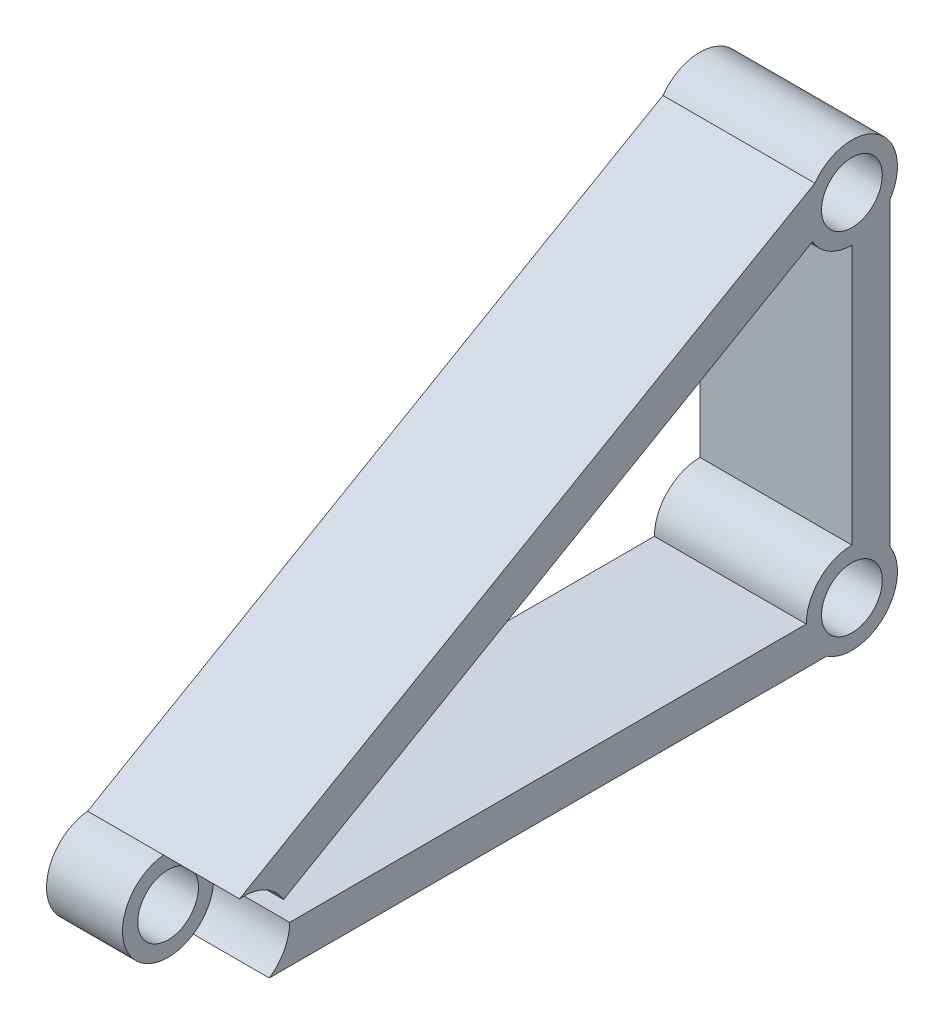
from build123d import *

# Parameters (mm, degrees)
SKETCH2_R           = 40
BOSS_EXTRUDE1_DEPTH = 200
CUT_EXTRUDE1_START  = 200
SKETCH4_R           = 60
CUT_EXTRUDE1_DEPTH  = 100


with BuildPart() as part:
    # Sketch2 → Boss-Extrude1 (new body)
    with BuildSketch(Plane(origin=(0, 0, 0), x_dir=(0, 0, -1), z_dir=(1, 0, 0))):
        with BuildLine():
            ThreePointArc((1495.529247778, 67.272238992), (1475.827854944, 88.899495683), (1468.695495681, 117.272238992))
            Line((1468.695495681, 117.272238992), (788.695495681, 117.272238992))
            ThreePointArc((788.695495681, 117.272238992), (781.563136418, 88.899495683), (761.861743585, 67.272238992))
            Line((761.861743585, 67.272238992), (1495.529247778, 67.272238992))
        make_face()
        with BuildLine():
            Line((780.657019908, 147.272238992), (1476.733971454, 549.152454344))
            ThreePointArc((1476.733971454, 549.152454344), (1468.769326722, 582.128067523), (1479.961523957, 614.152454344))
            Line((1479.961523957, 614.152454344), (722.751592411, 176.977096532))
            ThreePointArc((722.751592411, 176.977096532), (756.081623557, 170.657630252), (780.657019908, 147.272238992))
        make_face()
        with BuildLine():
            ThreePointArc((1578.695495681, 545.98620644), (1557.068238991, 526.284813607), (1528.695495681, 519.152454344))
            Line((1528.695495681, 519.152454344), (1528.695495681, 177.272238992))
            ThreePointArc((1528.695495681, 177.272238992), (1557.068238991, 170.139879729), (1578.695495681, 150.438486896))
            Line((1578.695495681, 150.438486896), (1578.695495681, 545.98620644))
        make_face()
        with BuildLine():
            ThreePointArc((780.657019908, 147.272238992), (670.739946104, 101.743096286), (788.695495681, 117.272238992))
            ThreePointArc((788.695495681, 117.272238992), (786.651045259, 132.801381698), (780.657019908, 147.272238992))
        make_face()
        with Locations((728.695495681, 117.272238992)):
            Circle(SKETCH2_R, mode=Mode.SUBTRACT)
        with BuildLine():
            ThreePointArc((1468.695495681, 117.272238992), (1486.26908881, 159.698645863), (1528.695495681, 177.272238992))
            ThreePointArc((1528.695495681, 177.272238992), (1571.121902553, 74.845832121), (1468.695495681, 117.272238992))
        make_face()
        with Locations((1528.695495681, 117.272238992)):
            Circle(SKETCH2_R, mode=Mode.SUBTRACT)
        with BuildLine():
            ThreePointArc((1528.695495681, 519.152454344), (1558.695495681, 631.113978571), (1476.733971454, 549.152454344))
            ThreePointArc((1476.733971454, 549.152454344), (1498.695495681, 527.190930117), (1528.695495681, 519.152454344))
        make_face()
        with Locations((1528.695495681, 579.152454344)):
            Circle(SKETCH2_R, mode=Mode.SUBTRACT)
    extrude(amount=BOSS_EXTRUDE1_DEPTH)

    # Sketch4 → Cut-Extrude1 (cut)
    with BuildSketch(Plane(origin=(0, 0, 0), x_dir=(0, 0, -1), z_dir=(1, 0, 0)).offset(CUT_EXTRUDE1_START)):
        with Locations((728.695495681, 117.272238992)):
            Circle(SKETCH4_R)
    extrude(amount=-CUT_EXTRUDE1_DEPTH, mode=Mode.SUBTRACT)


solid = part.part
